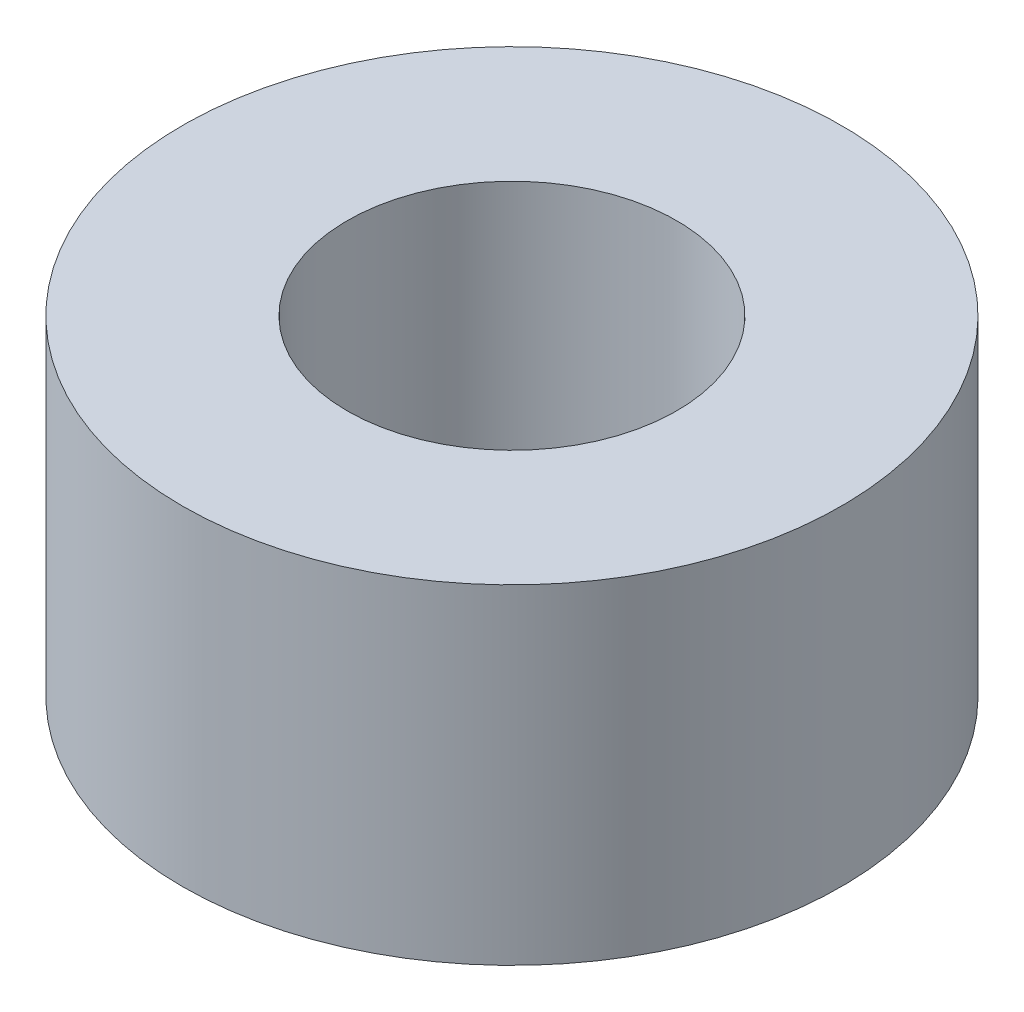
from build123d import *

# Parameters (mm, degrees)
CROQUIS1_R              = 3.175
CROQUIS1_R_2            = 1.5875
SALIENTE_EXTRUIR1_DEPTH = 3.175


with BuildPart() as part:
    # Croquis1 → Saliente-Extruir1 (new body)
    with BuildSketch(Plane(origin=(0, 0, 0), x_dir=(1, 0, 0), z_dir=(0, 1, 0))):
        Circle(CROQUIS1_R)
        Circle(CROQUIS1_R_2, mode=Mode.SUBTRACT)
    extrude(amount=SALIENTE_EXTRUIR1_DEPTH)


solid = part.part
